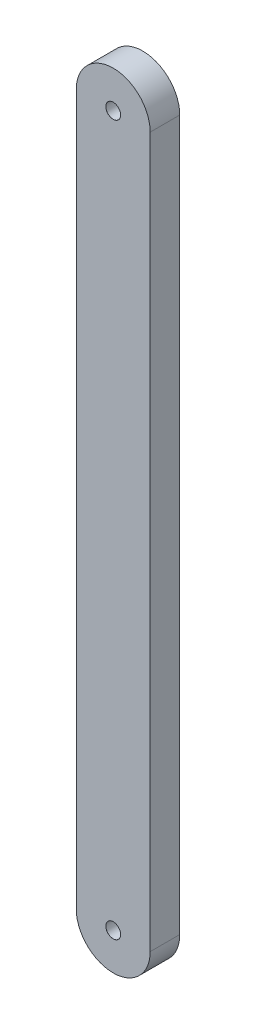
from build123d import *

# Parameters (mm, degrees)
BOSS_EXTRUDE1_DEPTH              = 20
F_10_0MM_DOWEL_HOLE1_D           = 10
F_10_0MM_DOWEL_HOLE1_DEPTH       = 20
F_10_0MM_DOWEL_HOLE1_CSINK_D     = 10.05
F_10_0MM_DOWEL_HOLE1_CSINK_ANGLE = 90
SCALE1_SCALE                     = 0.125


with BuildPart() as part:
    # Sketch1 → Boss-Extrude1 (new body)
    with BuildSketch(Plane.XY):
        with BuildLine():
            Line((0, 0), (0, 480))
            ThreePointArc((0, 480), (25, 505), (50, 480))
            Line((50, 480), (50, 0))
            ThreePointArc((50, 0), (25, -25), (0, 0))
        make_face()
    extrude(amount=BOSS_EXTRUDE1_DEPTH)

    # Ø10.0mm Dowel Hole1
    with Locations(Plane.XY.offset(20)):
        with Locations((25, 480), (25, 0)):
            CounterSinkHole(F_10_0MM_DOWEL_HOLE1_D / 2, F_10_0MM_DOWEL_HOLE1_CSINK_D / 2, depth=F_10_0MM_DOWEL_HOLE1_DEPTH, counter_sink_angle=F_10_0MM_DOWEL_HOLE1_CSINK_ANGLE)


with BuildPart() as part_1:
    # Scale1: scaled about (25, 240, 9.999999619)
    add(part.part.scale(SCALE1_SCALE).moved(Location((21.875, 210, 8.749999667))))


solid = part_1.part
